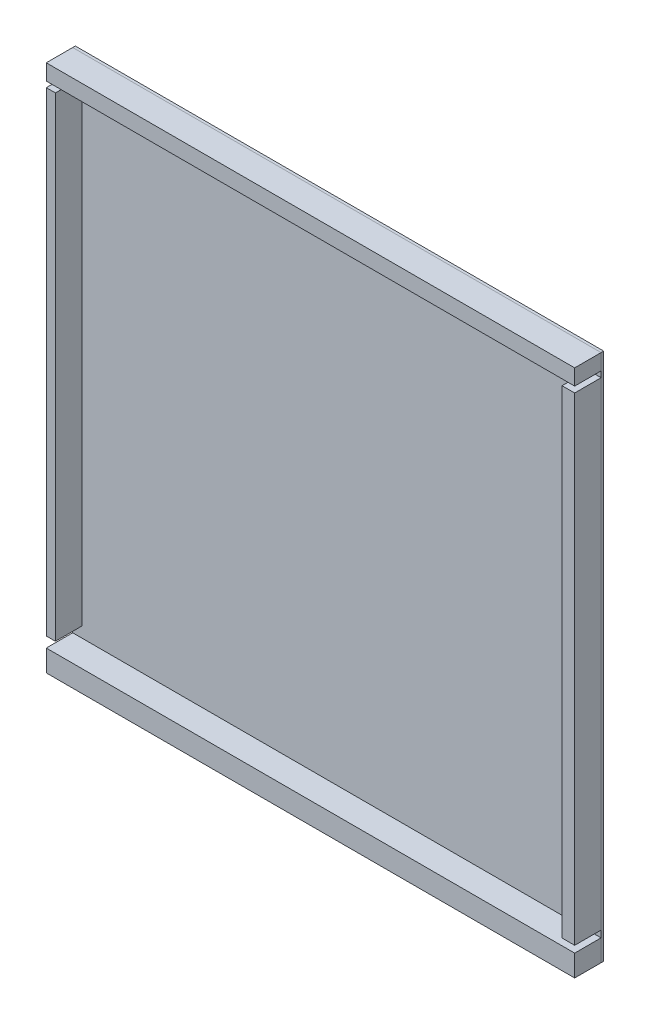
from build123d import *

# Parameters (mm, degrees)
SKETCH1_W           = 2000
SKETCH1_H           = 2000
BOSS_EXTRUDE1_DEPTH = 10
SKETCH2_W           = 2000
SKETCH2_H           = 2000
BOSS_EXTRUDE2_DEPTH = 10
SKETCH3_W           = 2000
SKETCH3_H           = 59.866245655
BOSS_EXTRUDE3_DEPTH = 100
SKETCH4_W           = 2000
SKETCH4_H           = 81.585108981
BOSS_EXTRUDE4_DEPTH = 100
SKETCH5_W           = 47.734318133
SKETCH5_H           = 1810.488542103
BOSS_EXTRUDE5_DEPTH = 100
SKETCH6_W           = 34.642183049
SKETCH6_H           = 1797.540465537
BOSS_EXTRUDE6_DEPTH = 100


with BuildPart() as part:
    # Sketch1 → Boss-Extrude1 (new body)
    with BuildSketch(Plane.XY):
        with Locations((750, 750)):
            Rectangle(SKETCH1_W, SKETCH1_H)
    extrude(amount=BOSS_EXTRUDE1_DEPTH)


with BuildPart() as body_2:
    # Sketch2 → Boss-Extrude2 (new body)
    with BuildSketch(Plane.XY.offset(10)):
        with Locations((750, 750)):
            Rectangle(SKETCH2_W, SKETCH2_H)
    extrude(amount=-BOSS_EXTRUDE2_DEPTH)


with BuildPart() as body_3:
    # Sketch3 → Boss-Extrude3 (new body)
    with BuildSketch(Plane.XY.offset(10)):
        with Locations((750, 1720.066877172)):
            Rectangle(SKETCH3_W, SKETCH3_H)
    extrude(amount=BOSS_EXTRUDE3_DEPTH)


with BuildPart() as body_4:
    # Sketch4 → Boss-Extrude4 (new body)
    with BuildSketch(Plane.XY.offset(10)):
        with Locations((750, -209.20744551)):
            Rectangle(SKETCH4_W, SKETCH4_H)
    extrude(amount=BOSS_EXTRUDE4_DEPTH)


with BuildPart() as body_5:
    # Sketch5 → Boss-Extrude5 (new body)
    with BuildSketch(Plane.XY.offset(10)):
        with Locations((1726.132840934, 762.3708112)):
            Rectangle(SKETCH5_W, SKETCH5_H)
    extrude(amount=BOSS_EXTRUDE5_DEPTH)


with BuildPart() as body_6:
    # Sketch6 → Boss-Extrude6 (new body)
    with BuildSketch(Plane.XY.offset(10)):
        with Locations((-232.678908476, 769.7788276)):
            Rectangle(SKETCH6_W, SKETCH6_H)
    extrude(amount=BOSS_EXTRUDE6_DEPTH)


solid = Compound([part.part, body_2.part, body_3.part, body_4.part, body_5.part, body_6.part])
